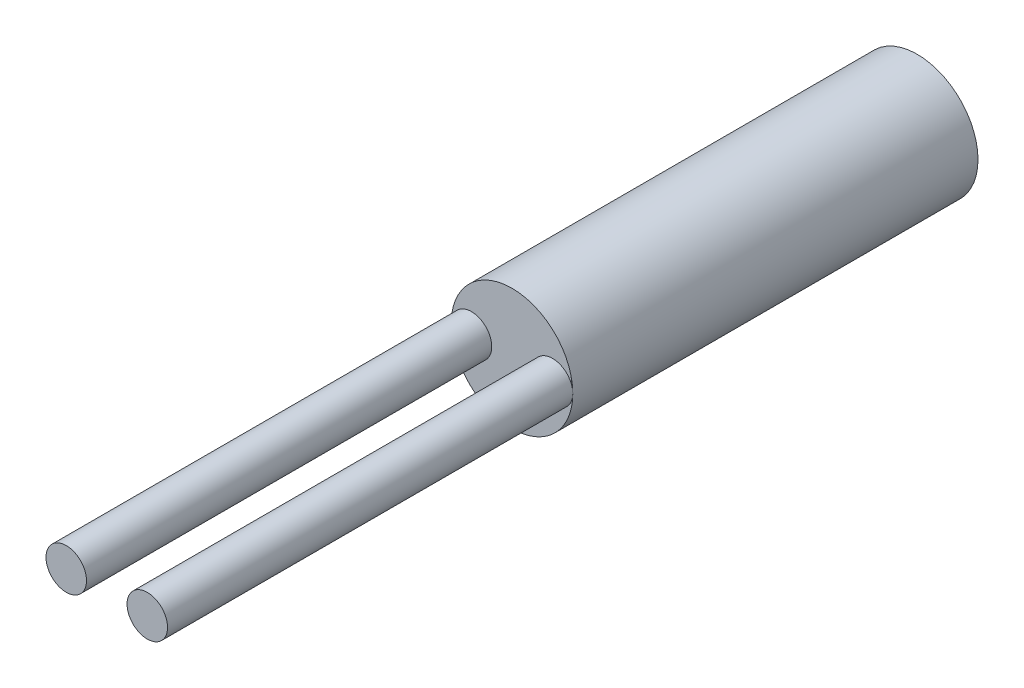
from build123d import *

# Parameters (mm, degrees)
SKETCH1_R           = 3
BOSS_EXTRUDE1_DEPTH = 20
SKETCH2_R           = 1
BOSS_EXTRUDE2_DEPTH = 20


with BuildPart() as part:
    # Sketch1 → Boss-Extrude1 (new body)
    with BuildSketch(Plane.XY):
        Circle(SKETCH1_R)
    extrude(amount=BOSS_EXTRUDE1_DEPTH)

    # Sketch2 → Boss-Extrude2 (add)
    with BuildSketch(Plane.XY.offset(20)):
        with Locations((-2, 0)):
            Circle(SKETCH2_R)
        with Locations((2, 0)):
            Circle(SKETCH2_R)
    extrude(amount=BOSS_EXTRUDE2_DEPTH)


solid = part.part
